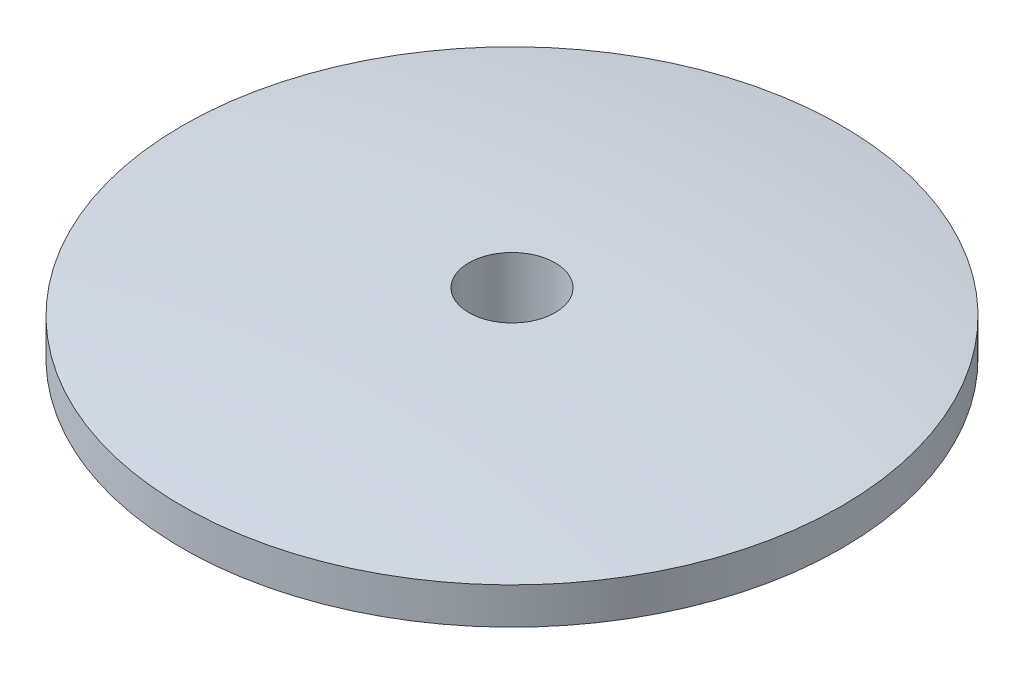
from build123d import *


with BuildPart() as part:
    # Sketch1 → Revolve1 (revolve)
    with BuildSketch(Plane.XY):
        with BuildLine():
            Line((0.1055, 0.148978695), (0.1055, 0))
            Line((0.1055, 0), (0.8051, 0))
            Line((0.8051, 0), (0.8051, 0.0895))
            ThreePointArc((0.8051, 0.0895), (0.456270226, 0.13065133), (0.1055, 0.148978695))
        make_face()
    revolve(axis=Axis((0, -203.342200931, 0), (0, 1, 0)))


solid = part.part
